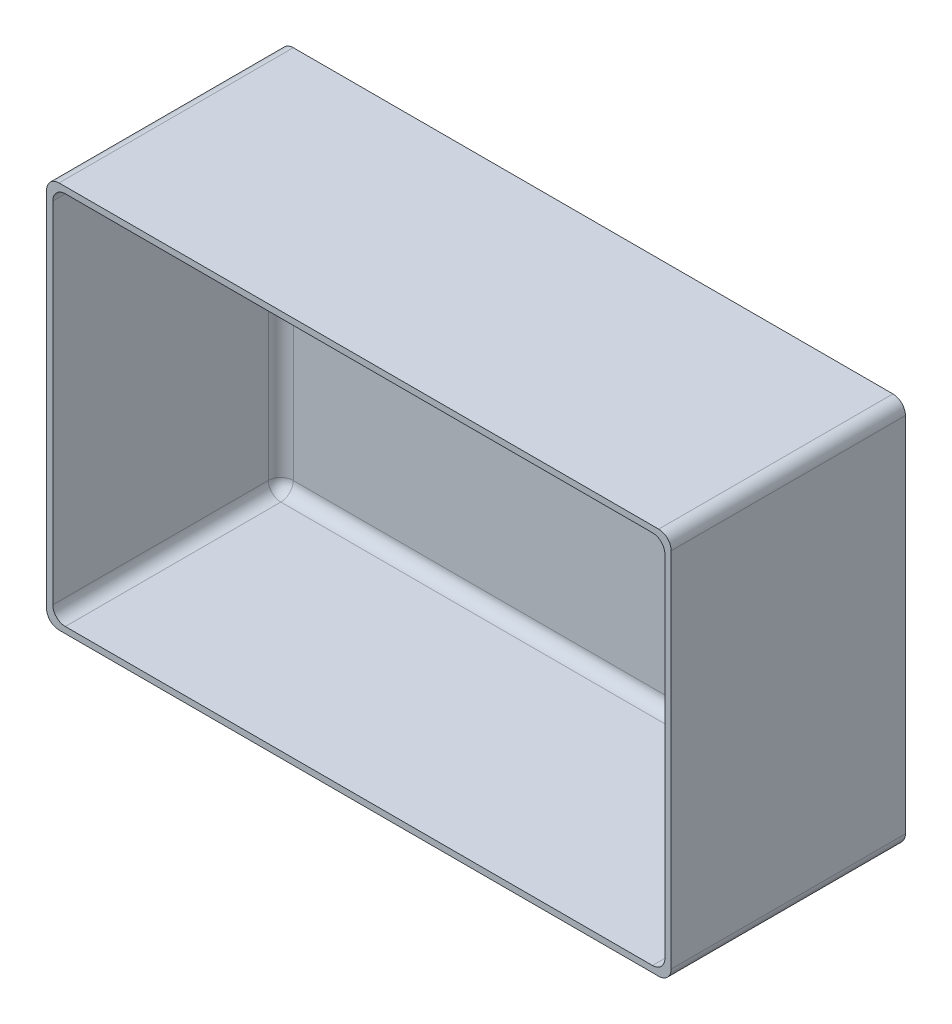
from build123d import *

# Parameters (mm, degrees)
ESQUISSE1_W        = 80
ESQUISSE1_H        = 49.6
BOSS_EXTRU_1_DEPTH = 30
COQUE1_T           = -0.8
CONG_1_R           = 1.6


with BuildPart() as part:
    # Esquisse1 → Boss.-Extru.1 (new body)
    with BuildSketch(Plane.XY):
        Rectangle(ESQUISSE1_W, ESQUISSE1_H)
    extrude(amount=BOSS_EXTRU_1_DEPTH)

    # Coque1
    coque1_openings = [part.faces().sort_by_distance(p)[0] for p in [
        (0, 0, 30),
    ]]
    offset(amount=COQUE1_T, openings=coque1_openings, kind=Kind.INTERSECTION)

    # Congé1
    cong_1_edges = [part.edges().sort_by_distance(p)[0] for p in [
        (39.2, 0, 0.8),
        (39.2, -24, 15.4),
        (0, 24, 0.8),
        (39.2, 24, 15.4),
        (-39.2, 0, 0.8),
        (-39.2, 24, 15.4),
        (0, -24, 0.8),
        (-39.2, -24, 15.4),
        (40, -24.8, 15),
        (-40, -24.8, 15),
        (-40, 24.8, 15),
        (40, 24.8, 15),
    ]]
    fillet(cong_1_edges, radius=CONG_1_R)


solid = part.part
